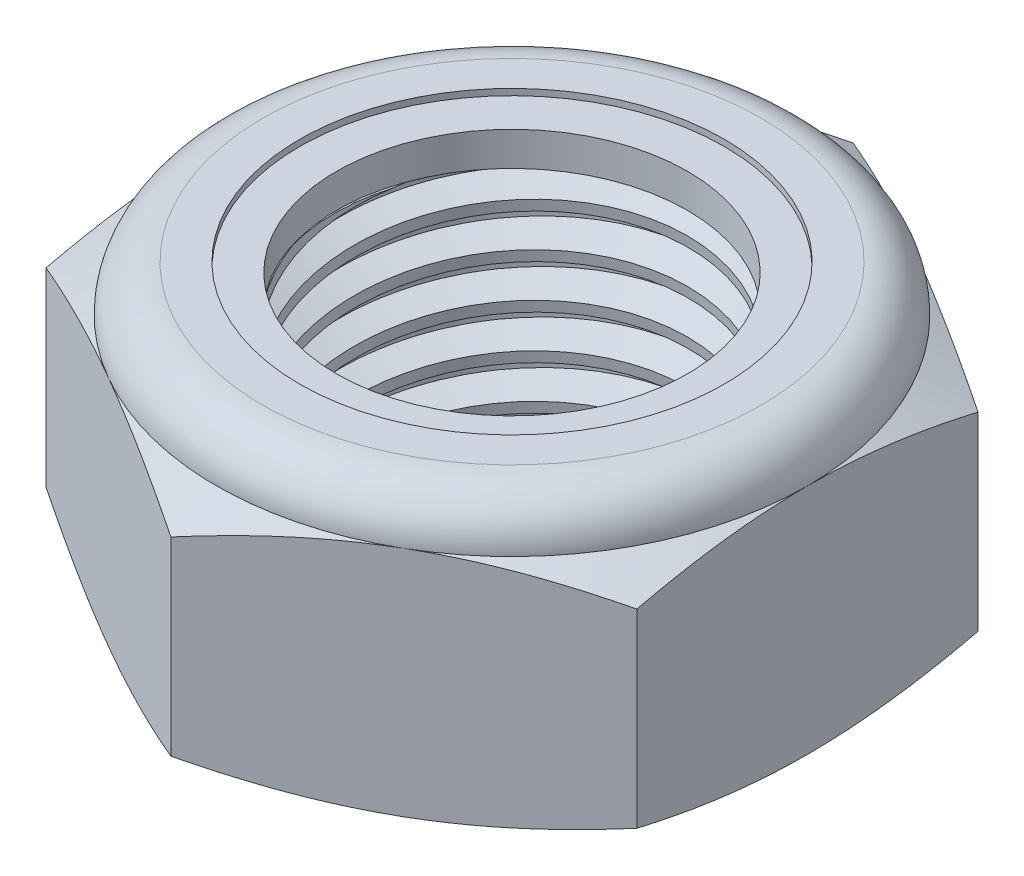
from build123d import *

# Parameters (mm, degrees)
EXTRUDE1_DEPTH      = 6.746875
SKETCH2_W           = 4.7625
SKETCH2_H           = 6.746875
LPATTERN1_COUNT     = 6
LPATTERN1_PITCH     = 1.058333333
LPATTERN1_COL_COUNT = 2
LPATTERN1_COL_PITCH = 1.058333333


with BuildPart() as part:
    # Sketch1 → Extrude1 (new body)
    with BuildSketch(Plane(origin=(0, 0, 0), x_dir=(1, 0, 0), z_dir=(0, 1, 0))):
        Polygon((0, 8.248891971), (-7.14375, 4.124445986), (-7.14375, -4.124445986), (0, -8.248891971), (7.14375, -4.124445986), (7.14375, 4.124445986), align=None)
    extrude(amount=EXTRUDE1_DEPTH)

    # Sketch4 → Cut-Revolve2 (revolve, cut)
    with BuildSketch(Plane(origin=(0, 0, 0), x_dir=(0, 0, -1), z_dir=(1, 0, 0))):
        Polygon((0, 6.746875), (4.7625, 6.746875), (4.244296017, 6.505232514), (4.244296017, 0.241642486), (4.7625, 0), (0, 0), align=None)
    revolve(axis=Axis((0, 6.746875, 0), (0, 1, 0)), mode=Mode.SUBTRACT)


with BuildPart() as body_2:
    # Sketch2 → Revolve1 (revolve)
    with BuildSketch(Plane(origin=(0, 0, 0), x_dir=(0, 0, -1), z_dir=(1, 0, 0))):
        with Locations((2.38125, 3.3734375)):
            Rectangle(SKETCH2_W, SKETCH2_H)
    revolve(axis=Axis((0, -4.7625, 0), (0, 1, 0)))

    # Sketch3 → Cut-Revolve1 (revolve, cut)
    with BuildSketch(Plane(origin=(0, 0, 0), x_dir=(0, 0, -1), z_dir=(1, 0, 0))):
        Polygon((4.777109171, 6.615392464), (4.879373365, 5.695014714), (4.273514358, 5.960461489), (4.244296017, 6.22342656), align=None)
    cut_revolve1 = revolve(axis=Axis((0, 6.746875, 0.125349185), (0, -0.993883735, -0.110431526)), mode=Mode.SUBTRACT)

    # LPattern1: Cut-Revolve1 ×6
    with Locations(*[(0, -i * LPATTERN1_PITCH, 0) for i in range(1, LPATTERN1_COUNT)]):
        add(cut_revolve1, mode=Mode.SUBTRACT)

    # LPattern1 col: Cut-Revolve1 ×2
    with Locations(*[(0, i * LPATTERN1_COL_PITCH, 0) for i in range(1, LPATTERN1_COL_COUNT)]):
        add(cut_revolve1, mode=Mode.SUBTRACT)


with BuildPart() as part_1:
    add(part.part)

    # Combine1: cut body 2
    add(body_2.part, mode=Mode.SUBTRACT)

    # Sketch5 → Cut-Revolve3 (revolve, cut)
    with BuildSketch(Plane(origin=(0, 0, 0), x_dir=(0, 0, -1), z_dir=(1, 0, 0))):
        with BuildLine():
            Line((0, 0), (7.14375, 0))
            Line((7.14375, 0), (8.248891971, 0.515336164))
            Line((8.248891971, 0.515336164), (8.248891971, 5.107059669))
            Line((8.248891971, 5.107059669), (7.14375, 5.622395833))
            ThreePointArc((7.14375, 5.622395833), (6.814397677, 6.417522677), (6.019270833, 6.746875))
            Line((6.019270833, 6.746875), (6.019270833, 8.016875))
            Line((6.019270833, 8.016875), (9.518891971, 8.016875))
            Line((9.518891971, 8.016875), (9.518891971, -1.27))
            Line((9.518891971, -1.27), (0, -1.27))
            Line((0, -1.27), (0, 0))
        make_face()
    revolve(axis=Axis((0, 0, 0), (0, 1, 0)), mode=Mode.SUBTRACT)

    # Sketch6 → Cut-Revolve4 (revolve, cut)
    with BuildSketch(Plane(origin=(0, 0, 0), x_dir=(0, 0, -1), z_dir=(1, 0, 0))):
        with BuildLine():
            Line((0, 5.622395833), (6.99135, 5.622395833))
            ThreePointArc((6.99135, 5.622395833), (6.706634604, 6.309759604), (6.019270833, 6.594475))
            Line((6.019270833, 6.594475), (5.131783425, 6.594475))
            Line((5.131783425, 6.594475), (5.131783425, 8.016875))
            Line((5.131783425, 8.016875), (0, 8.016875))
            Line((0, 8.016875), (0, 5.622395833))
        make_face()
    revolve(axis=Axis((0, 8.016875, 0), (0, 1, 0)), mode=Mode.SUBTRACT)


with BuildPart() as body_2_2:
    # Sketch7 → Revolve2 (revolve)
    with BuildSketch(Plane(origin=(0, 0, 0), x_dir=(0, 0, -1), z_dir=(1, 0, 0))):
        with BuildLine():
            Line((4.244296017, 5.698595833), (6.91190348, 5.698595833))
            ThreePointArc((6.91190348, 5.698595833), (6.625213689, 6.282269107), (6.019270833, 6.518275))
            Line((6.019270833, 6.518275), (4.244296017, 6.518275))
            Line((4.244296017, 6.518275), (4.244296017, 5.698595833))
        make_face()
    revolve(axis=Axis((0, 5.698595833, 0), (0, 1, 0)))


solid = Compound([part_1.part, body_2_2.part])
